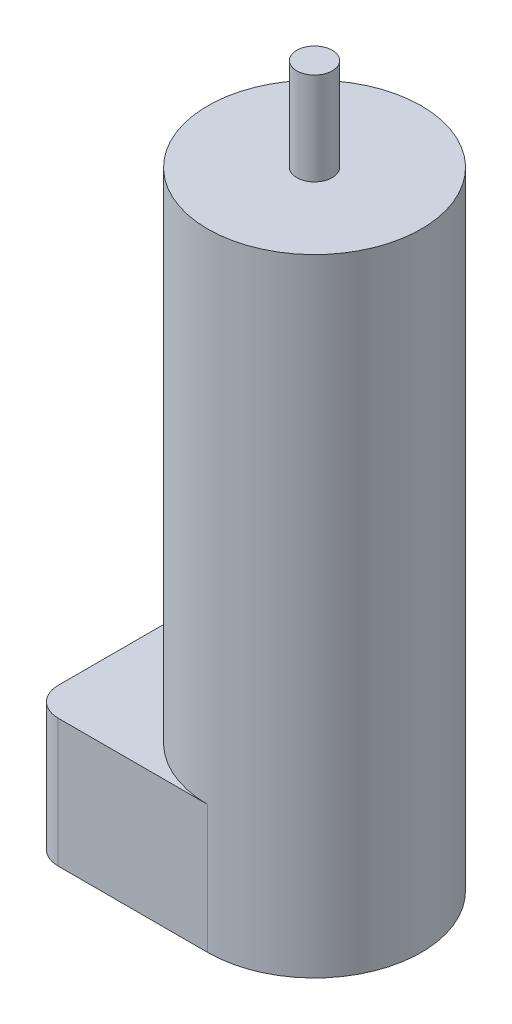
from build123d import *

# Parameters (mm, degrees)
SKETCH1_R           = 15
BOSS_EXTRUDE1_DEPTH = 88
SKETCH2_R           = 2.5
BOSS_EXTRUDE2_DEPTH = 13
BOSS_EXTRUDE3_DEPTH = 18
FILLET1_R           = 4


with BuildPart() as part:
    # Sketch1 → Boss-Extrude1 (new body)
    with BuildSketch(Plane(origin=(0, 0, 0), x_dir=(1, 0, 0), z_dir=(0, 1, 0))):
        Circle(SKETCH1_R)
    extrude(amount=BOSS_EXTRUDE1_DEPTH)

    # Sketch2 → Boss-Extrude2 (add)
    with BuildSketch(Plane(origin=(0, 88, 0), x_dir=(1, 0, 0), z_dir=(0, 1, 0))):
        Circle(SKETCH2_R)
    extrude(amount=BOSS_EXTRUDE2_DEPTH)

    # Sketch3 → Boss-Extrude3 (add)
    with BuildSketch(Plane(origin=(0, 18, 0), x_dir=(-1, 0, 0), z_dir=(0, -1, 0))):
        with BuildLine():
            Line((0, 15), (25, 15))
            Line((25, 15), (25, -15))
            Line((25, -15), (0, -15))
            ThreePointArc((0, -15), (-15, 0), (0, 15))
        make_face()
    extrude(amount=BOSS_EXTRUDE3_DEPTH)

    # Fillet1
    fillet1_edges = [part.edges().sort_by_distance(p)[0] for p in [
        (-25, 9, -15),
        (-25, 9, 15),
    ]]
    fillet(fillet1_edges, radius=FILLET1_R)


solid = part.part
